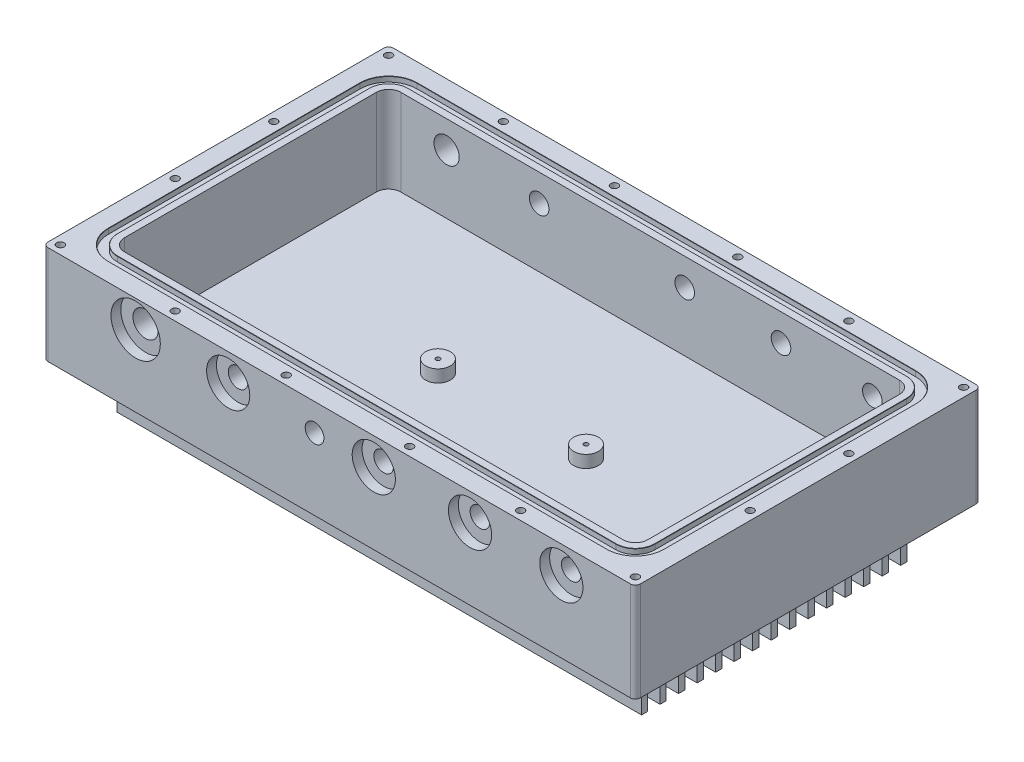
from build123d import *

# Parameters (mm, degrees)
SKETCH1_W                                = 304.8
SKETCH1_H                                = 177.8
BOSS_EXTRUDE1_DEPTH                      = 76.2
SKETCH2_W                                = 269.24
SKETCH2_H                                = 142.24
CUT_EXTRUDE1_DEPTH                       = 38.1
SKETCH3_W                                = 304.8
SKETCH3_H                                = 177.8
SKETCH3_W_2                              = 269.875
SKETCH3_H_2                              = 142.875
CUT_EXTRUDE2_DEPTH                       = 25.4
CUT_EXTRUDE3_DEPTH                       = 288.3375
F_10_24_TAPPED_HOLE1_D                   = 3.7973
F_10_24_TAPPED_HOLE1_DEPTH               = 14.9606
F_10_24_TAPPED_HOLE1_TIP                 = 1.140824014
F_10_24_TAPPED_HOLE2_D                   = 3.7973
FILLET1_R                                = 6.35
CUT_EXTRUDE9_DEPTH                       = 2.6416
CBORE_FOR_3_8_HEX_HEAD_BOLT2_D           = 10.0838
CBORE_FOR_3_8_HEX_HEAD_BOLT2_DEPTH       = 17.78
CBORE_FOR_3_8_HEX_HEAD_BOLT2_CBORE_D     = 22.225
CBORE_FOR_3_8_HEX_HEAD_BOLT2_CBORE_DEPTH = 5.08
CBORE_FOR_1_2_HEX_HEAD_BOLT1_D           = 13.0048
CBORE_FOR_1_2_HEX_HEAD_BOLT1_DEPTH       = 17.78
CBORE_FOR_1_2_HEX_HEAD_BOLT1_CBORE_D     = 25.4
CBORE_FOR_1_2_HEX_HEAD_BOLT1_CBORE_DEPTH = 5.08
CBORE_FOR_3_8_HEX_HEAD_BOLT1_D           = 10.0838
CBORE_FOR_3_8_HEX_HEAD_BOLT1_DEPTH       = 17.78
CBORE_FOR_3_8_HEX_HEAD_BOLT1_CBORE_D     = 22.225
CBORE_FOR_3_8_HEX_HEAD_BOLT1_CBORE_DEPTH = 5.08
CHAMFER1_SIZE                            = 0.127
F_4_40_TAPPED_HOLE1_D                    = 2.2606
F_4_40_TAPPED_HOLE1_DEPTH                = 7.5946
F_4_40_TAPPED_HOLE1_TIP                  = 0.679152758
SKETCH38_R                               = 6.35
CUT_EXTRUDE11_DEPTH                      = 6.35
FILLET3_R                                = 2.54
CUT_EXTRUDE12_REACH                      = 179.8
SKETCH39_R                               = 6.5024
SKETCH40_R                               = 12.7
CUT_EXTRUDE13_DEPTH                      = 5.08


with BuildPart() as part:
    # Sketch1 → Boss-Extrude1 (new body)
    with BuildSketch(Plane(origin=(0, 0, 0), x_dir=(1, 0, 0), z_dir=(0, 1, 0))):
        with Locations((152.4, 88.9)):
            Rectangle(SKETCH1_W, SKETCH1_H)
    extrude(amount=BOSS_EXTRUDE1_DEPTH)

    # Sketch2 → Cut-Extrude1 (cut)
    with BuildSketch(Plane(origin=(0, 76.2, 0), x_dir=(1, 0, 0), z_dir=(0, 1, 0))):
        with Locations((152.4, 88.9)):
            Rectangle(SKETCH2_W, SKETCH2_H)
    extrude(amount=-CUT_EXTRUDE1_DEPTH, mode=Mode.SUBTRACT)

    # Sketch3 → Cut-Extrude2 (cut)
    with BuildSketch(Plane.XZ):
        with Locations((152.4, -88.9)):
            Rectangle(SKETCH3_W, SKETCH3_H)
        with Locations((152.4, -88.9)):
            Rectangle(SKETCH3_W_2, SKETCH3_H_2, mode=Mode.SUBTRACT)
    extrude(amount=-CUT_EXTRUDE2_DEPTH, mode=Mode.SUBTRACT)

    # Sketch4 → Cut-Extrude3 (cut, through all)
    with BuildSketch(Plane(origin=(287.3375, 0, 0), x_dir=(0, 0, -1), z_dir=(1, 0, 0))):
        Polygon((87.3125, 0), (90.4875, 0), (90.4875, 25.4), (96.8375, 25.4), (96.8375, 0), (100.0125, 0), (100.0125, 25.4), (106.3625, 25.4), (106.3625, 0), (109.5375, 0), (109.5375, 25.4), (115.8875, 25.4), (115.8875, 0), (119.0625, 0), (119.0625, 25.4), (125.4125, 25.4), (125.4125, 0), (128.5875, 0), (128.5875, 25.4), (134.9375, 25.4), (134.9375, 0), (138.1125, 0), (138.1125, 25.4), (144.4625, 25.4), (144.4625, 0), (147.6375, 0), (147.6375, 25.4), (153.9875, 25.4), (153.9875, 0), (157.1625, 0), (157.1625, 25.4), (163.5125, 25.4), (163.5125, 0), (166.6875, 0), (166.6875, 25.4), (173.0375, 25.4), (173.0375, 0), (176.2125, 0), (176.2125, 25.4), (182.5625, 25.4), (182.5625, 0), (185.7375, 0), (185.7375, 25.4), (192.0875, 25.4), (192.0875, 0), (195.2625, 0), (195.2625, 25.4), (201.6125, 25.4), (201.6125, 0), (204.7875, 0), (204.7875, 25.4), (211.1375, 25.4), (211.1375, 0), (214.3125, 0), (214.3125, 25.4), (220.6625, 25.4), (220.6625, 0), (223.8375, 0), (223.8375, 25.4), (230.1875, 25.4), (230.1875, 0), (230.1875, -16.051535004), (-52.3875, -16.051535004), (-52.3875, 0), (-52.3875, 25.4), (-46.0375, 25.4), (-46.0375, 0), (-42.8625, 0), (-42.8625, 25.4), (-36.5125, 25.4), (-36.5125, 0), (-33.3375, 0), (-33.3375, 25.4), (-26.9875, 25.4), (-26.9875, 0), (-23.8125, 0), (-23.8125, 25.4), (-17.4625, 25.4), (-17.4625, 0), (-14.2875, 0), (-14.2875, 25.4), (-7.9375, 25.4), (-7.9375, 0), (-4.7625, 0), (-4.7625, 25.4), (1.5875, 25.4), (1.5875, 0), (4.7625, 0), (4.7625, 25.4), (11.1125, 25.4), (11.1125, 0), (14.2875, 0), (14.2875, 25.4), (20.6375, 25.4), (20.6375, 0), (23.8125, 0), (23.8125, 25.4), (30.1625, 25.4), (30.1625, 0), (33.3375, 0), (33.3375, 25.4), (39.6875, 25.4), (39.6875, 0), (42.8625, 0), (42.8625, 25.4), (49.2125, 25.4), (49.2125, 0), (52.3875, 0), (52.3875, 25.4), (58.7375, 25.4), (58.7375, 0), (61.9125, 0), (61.9125, 25.4), (68.2625, 25.4), (68.2625, 0), (71.4375, 0), (71.4375, 25.4), (77.7875, 25.4), (77.7875, 0), (80.9625, 0), (80.9625, 25.4), (87.3125, 25.4), align=None)
    extrude(amount=-CUT_EXTRUDE3_DEPTH, mode=Mode.SUBTRACT)

    # #10-24 Tapped Hole1
    with Locations(Plane(origin=(0, 76.2, 0), x_dir=(1, 0, 0), z_dir=(0, 1, 0))):
        with Locations((63.5, 173.355), (120.65, 173.355), (184.15, 173.355), (241.3, 173.355), (241.3, 4.445), (184.15, 4.445), (120.65, 4.445), (63.5, 4.445)):
            Hole(F_10_24_TAPPED_HOLE1_D / 2, depth=F_10_24_TAPPED_HOLE1_DEPTH)
            with Locations((0, 0, -(F_10_24_TAPPED_HOLE1_DEPTH + F_10_24_TAPPED_HOLE1_TIP / 2))):  # 118° drill point
                Cone(0, F_10_24_TAPPED_HOLE1_D / 2, F_10_24_TAPPED_HOLE1_TIP, mode=Mode.SUBTRACT)

    # #10-24 Tapped Hole2 (through all)
    with Locations(Plane(origin=(0, 76.2, 0), x_dir=(1, 0, 0), z_dir=(0, 1, 0))):
        with Locations((4.445, 173.355), (4.445, 114.3), (4.445, 63.5), (4.445, 4.445), (300.355, 173.355), (300.355, 114.3), (300.355, 63.5), (300.355, 4.445)):
            Hole(F_10_24_TAPPED_HOLE2_D / 2)

    # Fillet1
    fillet1_edges = [part.edges().sort_by_distance(p)[0] for p in [
        (17.78, 57.15, -17.78),
        (17.78, 57.15, -160.02),
        (287.02, 57.15, -160.02),
        (287.02, 57.15, -17.78),
    ]]
    fillet(fillet1_edges, radius=FILLET1_R)

    # Sketch10 → Cut-Extrude9 (cut)
    with BuildSketch(Plane(origin=(0, 76.2, 0), x_dir=(1, 0, 0), z_dir=(0, 1, 0))):
        with BuildLine():
            Line((280.67, 168.3258), (24.13, 168.3258))
            ThreePointArc((24.13, 168.3258), (13.766784436, 164.033215564), (9.4742, 153.67))
            Line((9.4742, 153.67), (9.4742, 24.13))
            ThreePointArc((9.4742, 24.13), (13.766784436, 13.766784436), (24.13, 9.4742))
            Line((24.13, 9.4742), (280.67, 9.4742))
            ThreePointArc((280.67, 9.4742), (291.033215564, 13.766784436), (295.3258, 24.13))
            Line((295.3258, 24.13), (295.3258, 153.67))
            ThreePointArc((295.3258, 153.67), (291.033215564, 164.033215564), (280.67, 168.3258))
        make_face()
        with BuildLine():
            Line((14.097, 153.67), (14.097, 24.13))
            ThreePointArc((14.097, 24.13), (17.035597664, 17.035597664), (24.13, 14.097))
            Line((24.13, 14.097), (280.67, 14.097))
            ThreePointArc((280.67, 14.097), (287.764402336, 17.035597664), (290.703, 24.13))
            Line((290.703, 24.13), (290.703, 153.67))
            ThreePointArc((290.703, 153.67), (287.764402336, 160.764402336), (280.67, 163.703))
            Line((280.67, 163.703), (24.13, 163.703))
            ThreePointArc((24.13, 163.703), (17.035597664, 160.764402336), (14.097, 153.67))
        make_face(mode=Mode.SUBTRACT)
    extrude(amount=-CUT_EXTRUDE9_DEPTH, mode=Mode.SUBTRACT)

    # CBORE for 3/8 Hex Head Bolt2
    with Locations(Plane(origin=(0, 0, -177.8), x_dir=(-1, 0, 0), z_dir=(0, 0, -1))):
        with Locations((-266.7, 62.23), (-219.71, 62.23), (-170.18, 62.23), (-95.25, 62.23)):
            CounterBoreHole(CBORE_FOR_3_8_HEX_HEAD_BOLT2_D / 2, CBORE_FOR_3_8_HEX_HEAD_BOLT2_CBORE_D / 2, CBORE_FOR_3_8_HEX_HEAD_BOLT2_CBORE_DEPTH, depth=CBORE_FOR_3_8_HEX_HEAD_BOLT2_DEPTH)

    # CBORE for 1/2 Hex Head Bolt1
    with Locations(Plane(origin=(0, 0, -177.8), x_dir=(-1, 0, 0), z_dir=(0, 0, -1))):
        with Locations((-47.625, 62.23)):
            CounterBoreHole(CBORE_FOR_1_2_HEX_HEAD_BOLT1_D / 2, CBORE_FOR_1_2_HEX_HEAD_BOLT1_CBORE_D / 2, CBORE_FOR_1_2_HEX_HEAD_BOLT1_CBORE_DEPTH, depth=CBORE_FOR_1_2_HEX_HEAD_BOLT1_DEPTH)

    # CBORE for 3/8 Hex Head Bolt1
    with Locations(Plane.XY):
        with Locations((95.25, 62.23), (170.18, 62.23), (219.71, 62.23), (266.7, 62.23)):
            CounterBoreHole(CBORE_FOR_3_8_HEX_HEAD_BOLT1_D / 2, CBORE_FOR_3_8_HEX_HEAD_BOLT1_CBORE_D / 2, CBORE_FOR_3_8_HEX_HEAD_BOLT1_CBORE_DEPTH, depth=CBORE_FOR_3_8_HEX_HEAD_BOLT1_DEPTH)

    # Chamfer1
    chamfer1_edges = [part.edges().sort_by_distance(p)[0] for p in [
        (291.033215564, 76.2, -164.033215564),
        (152.4, 76.2, -168.3258),
        (13.766784436, 76.2, -164.033215564),
        (9.4742, 76.2, -88.9),
        (13.766784436, 76.2, -13.766784436),
        (152.4, 76.2, -9.4742),
        (291.033215564, 76.2, -13.766784436),
        (295.3258, 76.2, -88.9),
        (17.035597664, 76.2, -160.764402336),
        (152.4, 76.2, -163.703),
        (287.764402336, 76.2, -160.764402336),
        (290.703, 76.2, -88.9),
        (287.764402336, 76.2, -17.035597664),
        (152.4, 76.2, -14.097),
        (17.035597664, 76.2, -17.035597664),
        (14.097, 76.2, -88.9),
    ]]
    chamfer(chamfer1_edges, length=CHAMFER1_SIZE)

    # Sketch35 → 1/8 NPT Tapped Hole1 (revolve, cut)
    with BuildSketch(Plane(origin=(139.7, 62.23, 0), x_dir=(0, -1, 0), z_dir=(1, 0, 0))):
        Polygon((0, 0), (0, 17.78), (4.2164, 17.78), (4.2164, 9.525), (4.537405144, 9.525), (4.8225964, 0), align=None)
    revolve(axis=Axis((139.7, 62.23, 6.35), (0, 0, -1)), mode=Mode.SUBTRACT)

    # #4-40 Tapped Hole1
    with Locations(Plane(origin=(0, 38.1, 0), x_dir=(1, 0, 0), z_dir=(0, 1, 0))):
        with Locations((114.3, 88.9), (190.5, 88.9)):
            Hole(F_4_40_TAPPED_HOLE1_D / 2, depth=F_4_40_TAPPED_HOLE1_DEPTH)
            with Locations((0, 0, -(F_4_40_TAPPED_HOLE1_DEPTH + F_4_40_TAPPED_HOLE1_TIP / 2))):  # 118° drill point
                Cone(0, F_4_40_TAPPED_HOLE1_D / 2, F_4_40_TAPPED_HOLE1_TIP, mode=Mode.SUBTRACT)

    # Sketch38 → Cut-Extrude11 (cut)
    with BuildSketch(Plane(origin=(0, 38.1, 0), x_dir=(1, 0, 0), z_dir=(0, 1, 0))):
        with BuildLine():
            Line((17.78, 153.67), (17.78, 24.13))
            ThreePointArc((17.78, 24.13), (19.639871939, 19.639871939), (24.13, 17.78))
            Line((24.13, 17.78), (280.67, 17.78))
            ThreePointArc((280.67, 17.78), (285.160128061, 19.639871939), (287.02, 24.13))
            Line((287.02, 24.13), (287.02, 153.67))
            ThreePointArc((287.02, 153.67), (285.160128061, 158.160128061), (280.67, 160.02))
            Line((280.67, 160.02), (24.13, 160.02))
            ThreePointArc((24.13, 160.02), (19.639871939, 158.160128061), (17.78, 153.67))
        make_face()
        with Locations((190.5, 88.9)):
            Circle(SKETCH38_R, mode=Mode.SUBTRACT)
        with Locations((114.3, 88.9)):
            Circle(SKETCH38_R, mode=Mode.SUBTRACT)
    extrude(amount=-CUT_EXTRUDE11_DEPTH, mode=Mode.SUBTRACT)

    # Fillet3
    fillet3_edges = [part.edges().sort_by_distance(p)[0] for p in [
        (0, 50.8, -177.8),
        (304.8, 50.8, -177.8),
        (304.8, 50.8, 0),
        (0, 50.8, 0),
    ]]
    fillet(fillet3_edges, radius=FILLET3_R)

    # Sketch39 → Cut-Extrude12 (cut, up to next)
    with BuildSketch(Plane.XY, mode=Mode.PRIVATE) as cut_extrude12_sk1:
        with Locations((47.625, 62.23)):
            Circle(SKETCH39_R)
    cut_extrude12_tool1 = extrude(cut_extrude12_sk1.sketch, amount=-CUT_EXTRUDE12_REACH, mode=Mode.PRIVATE) & part.part
    add(cut_extrude12_tool1.solids().sort_by_distance((47.625, 62.23, 0))[0], mode=Mode.SUBTRACT)

    # Sketch40 → Cut-Extrude13 (cut)
    with BuildSketch(Plane.XY):
        with Locations((47.625, 62.23)):
            Circle(SKETCH40_R)
    extrude(amount=-CUT_EXTRUDE13_DEPTH, mode=Mode.SUBTRACT)


solid = part.part
